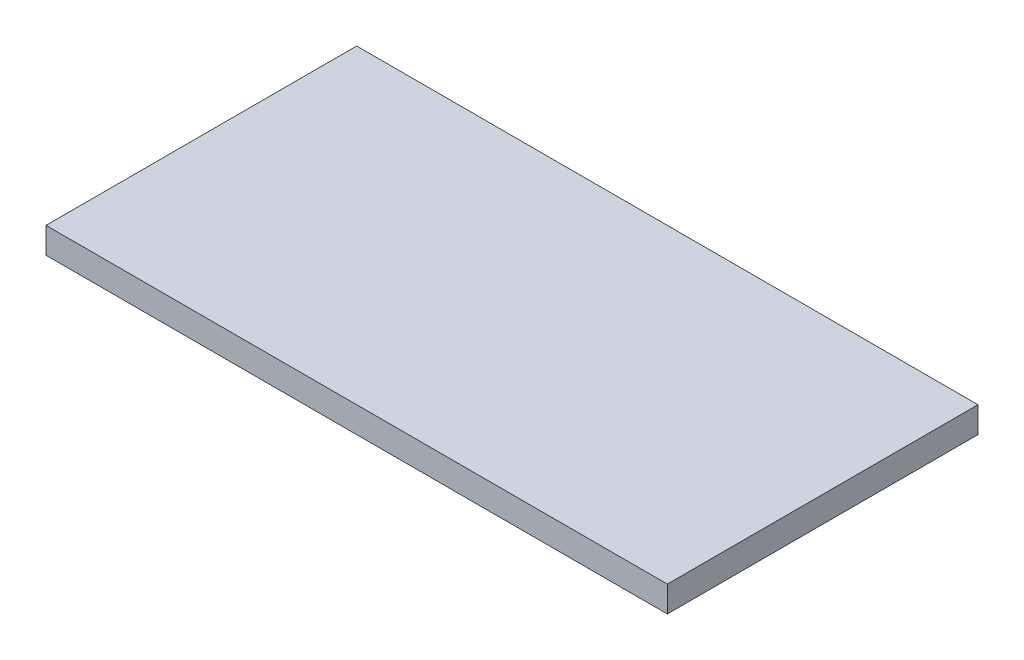
from build123d import *

# Parameters (mm, degrees)
SKETCH1_W           = 304.8
SKETCH1_H           = 152.4
BOSS_EXTRUDE1_DEPTH = 12.7


with BuildPart() as part:
    # Sketch1 → Boss-Extrude1 (new body)
    with BuildSketch(Plane(origin=(0, 0, 0), x_dir=(1, 0, 0), z_dir=(0, 1, 0))):
        with Locations((96.403902054, 52.676472888)):
            Rectangle(SKETCH1_W, SKETCH1_H)
    extrude(amount=BOSS_EXTRUDE1_DEPTH)


solid = part.part
